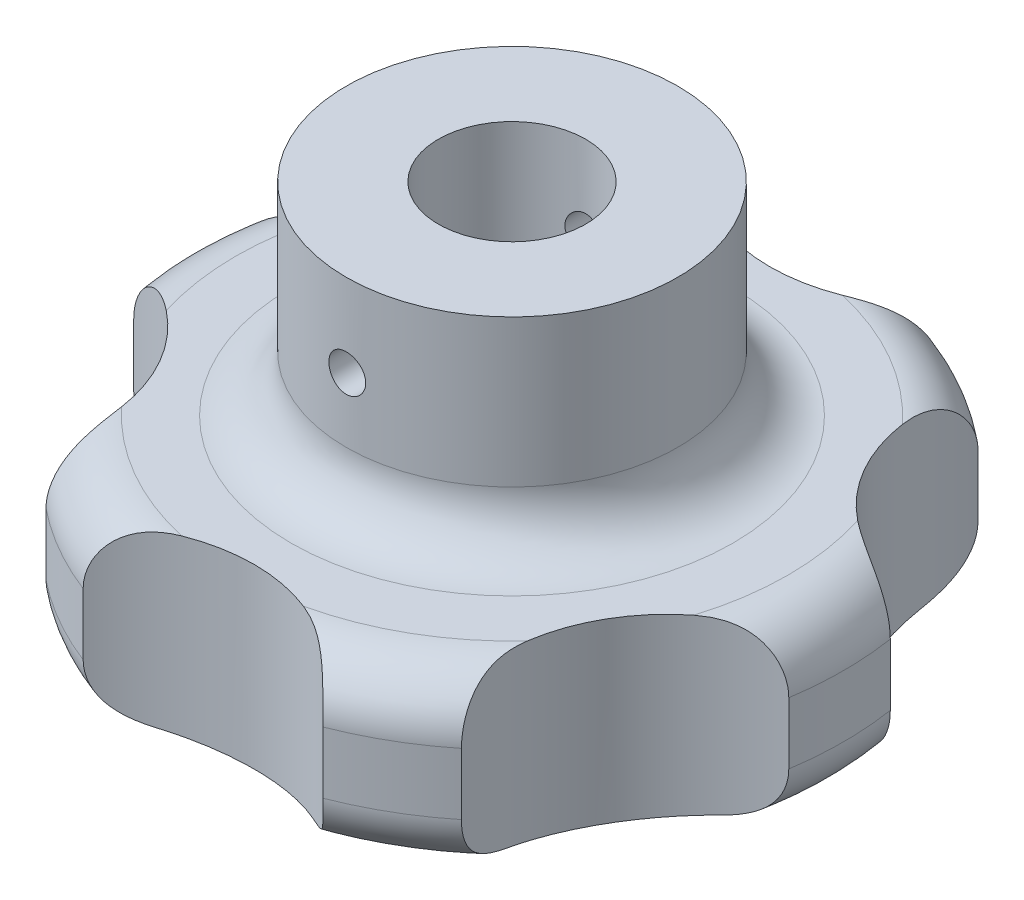
from build123d import *

# Parameters (mm, degrees)
CUT_EXTRUDE1_REACH      = 36.925
SKETCH3_R               = 1.5875
CUT_EXTRUDE2_DEPTH      = 27.642391404
CUT_EXTRUDE2_DEPTH_BACK = 27.642391404


with BuildPart() as part:
    # Sketch1 → Revolve1 (revolve)
    with BuildSketch(Plane.XY):
        with BuildLine():
            Line((0, 14.2875), (6.35, 16.598710988))
            Line((6.35, 16.598710988), (6.35, 34.925))
            Line((6.35, 34.925), (14.2875, 34.925))
            Line((14.2875, 34.925), (14.2875, 22.225))
            ThreePointArc((14.2875, 22.225), (15.682403955, 18.857403955), (19.05, 17.4625))
            Line((19.05, 17.4625), (23.8125, 17.4625))
            ThreePointArc((23.8125, 17.4625), (27.180096045, 16.067596045), (28.575, 12.7))
            Line((28.575, 12.7), (28.575, 7.382140173))
            ThreePointArc((28.575, 7.382140173), (27.528152482, 4.402990482), (24.847826087, 2.733537572))
            ThreePointArc((24.847826087, 2.733537572), (12.498866838, 0.685439631), (0, 0))
            Line((0, 0), (0, 14.2875))
        make_face()
    revolve(axis=Axis((0, 0, 0), (0, 1, 0)))

    # Sketch2 → Cut-Extrude1 (cut, up to next)
    with BuildSketch(Plane(origin=(0, 0, 0), x_dir=(1, 0, 0), z_dir=(0, 1, 0)), mode=Mode.PRIVATE) as cut_extrude1_sk1:
        with BuildLine():
            ThreePointArc((-28.238101688, -4.374955775), (-24.746675913, -14.2875), (-17.907873686, -22.267435529))
            ThreePointArc((-17.907873686, -22.267435529), (-19.247414599, -11.1125), (-28.238101688, -4.374955775))
        make_face()
    cut_extrude1_tool1 = extrude(cut_extrude1_sk1.sketch, amount=CUT_EXTRUDE1_REACH, mode=Mode.PRIVATE) & part.part
    add(cut_extrude1_tool1.solids().sort_by_distance((-22.184175, 0, 12.808039))[0], mode=Mode.SUBTRACT)
    # Sketch2 → Cut-Extrude1 (cut, up to next)
    with BuildSketch(Plane(origin=(0, 0, 0), x_dir=(1, 0, 0), z_dir=(0, 1, 0)), mode=Mode.PRIVATE) as cut_extrude1_sk2:
        with BuildLine():
            ThreePointArc((10.330228003, -26.642391304), (0, -22.225), (-10.330228003, -26.642391304))
            ThreePointArc((-10.330228003, -26.642391304), (0, -28.575), (10.330228003, -26.642391304))
        make_face()
    cut_extrude1_tool2 = extrude(cut_extrude1_sk2.sketch, amount=CUT_EXTRUDE1_REACH, mode=Mode.PRIVATE) & part.part
    add(cut_extrude1_tool2.solids().sort_by_distance((0, 0, 25.616079))[0], mode=Mode.SUBTRACT)
    # Sketch2 → Cut-Extrude1 (cut, up to next)
    with BuildSketch(Plane(origin=(0, 0, 0), x_dir=(1, 0, 0), z_dir=(0, 1, 0)), mode=Mode.PRIVATE) as cut_extrude1_sk3:
        with BuildLine():
            ThreePointArc((28.238101688, -4.374955775), (19.247414599, -11.1125), (17.907873686, -22.267435529))
            ThreePointArc((17.907873686, -22.267435529), (24.746675913, -14.2875), (28.238101688, -4.374955775))
        make_face()
    cut_extrude1_tool3 = extrude(cut_extrude1_sk3.sketch, amount=CUT_EXTRUDE1_REACH, mode=Mode.PRIVATE) & part.part
    add(cut_extrude1_tool3.solids().sort_by_distance((22.184175, 0, 12.808039))[0], mode=Mode.SUBTRACT)
    # Sketch2 → Cut-Extrude1 (cut, up to next)
    with BuildSketch(Plane(origin=(0, 0, 0), x_dir=(1, 0, 0), z_dir=(0, 1, 0)), mode=Mode.PRIVATE) as cut_extrude1_sk4:
        with BuildLine():
            ThreePointArc((17.907873686, 22.267435529), (19.247414599, 11.1125), (28.238101688, 4.374955775))
            ThreePointArc((28.238101688, 4.374955775), (24.746675913, 14.2875), (17.907873686, 22.267435529))
        make_face()
    cut_extrude1_tool4 = extrude(cut_extrude1_sk4.sketch, amount=CUT_EXTRUDE1_REACH, mode=Mode.PRIVATE) & part.part
    add(cut_extrude1_tool4.solids().sort_by_distance((22.184175, 0, -12.808039))[0], mode=Mode.SUBTRACT)
    # Sketch2 → Cut-Extrude1 (cut, up to next)
    with BuildSketch(Plane(origin=(0, 0, 0), x_dir=(1, 0, 0), z_dir=(0, 1, 0)), mode=Mode.PRIVATE) as cut_extrude1_sk5:
        with BuildLine():
            ThreePointArc((10.330228003, 26.642391304), (0, 28.575), (-10.330228003, 26.642391304))
            ThreePointArc((-10.330228003, 26.642391304), (0, 22.225), (10.330228003, 26.642391304))
        make_face()
    cut_extrude1_tool5 = extrude(cut_extrude1_sk5.sketch, amount=CUT_EXTRUDE1_REACH, mode=Mode.PRIVATE) & part.part
    add(cut_extrude1_tool5.solids().sort_by_distance((0, 0, -25.616079))[0], mode=Mode.SUBTRACT)
    # Sketch2 → Cut-Extrude1 (cut, up to next)
    with BuildSketch(Plane(origin=(0, 0, 0), x_dir=(1, 0, 0), z_dir=(0, 1, 0)), mode=Mode.PRIVATE) as cut_extrude1_sk6:
        with BuildLine():
            ThreePointArc((-17.907873686, 22.267435529), (-24.746675913, 14.2875), (-28.238101688, 4.374955775))
            ThreePointArc((-28.238101688, 4.374955775), (-19.247414599, 11.1125), (-17.907873686, 22.267435529))
        make_face()
    cut_extrude1_tool6 = extrude(cut_extrude1_sk6.sketch, amount=CUT_EXTRUDE1_REACH, mode=Mode.PRIVATE) & part.part
    add(cut_extrude1_tool6.solids().sort_by_distance((-22.184175, 0, -12.808039))[0], mode=Mode.SUBTRACT)

    # Sketch3 → Cut-Extrude2 (cut, two sides)
    with BuildSketch(Plane.XY) as cut_extrude2_sk:
        with Locations((0, 27.78125)):
            Circle(SKETCH3_R)
    extrude(amount=CUT_EXTRUDE2_DEPTH, mode=Mode.SUBTRACT)
    extrude(cut_extrude2_sk.sketch, amount=-CUT_EXTRUDE2_DEPTH_BACK, mode=Mode.SUBTRACT)


solid = part.part
